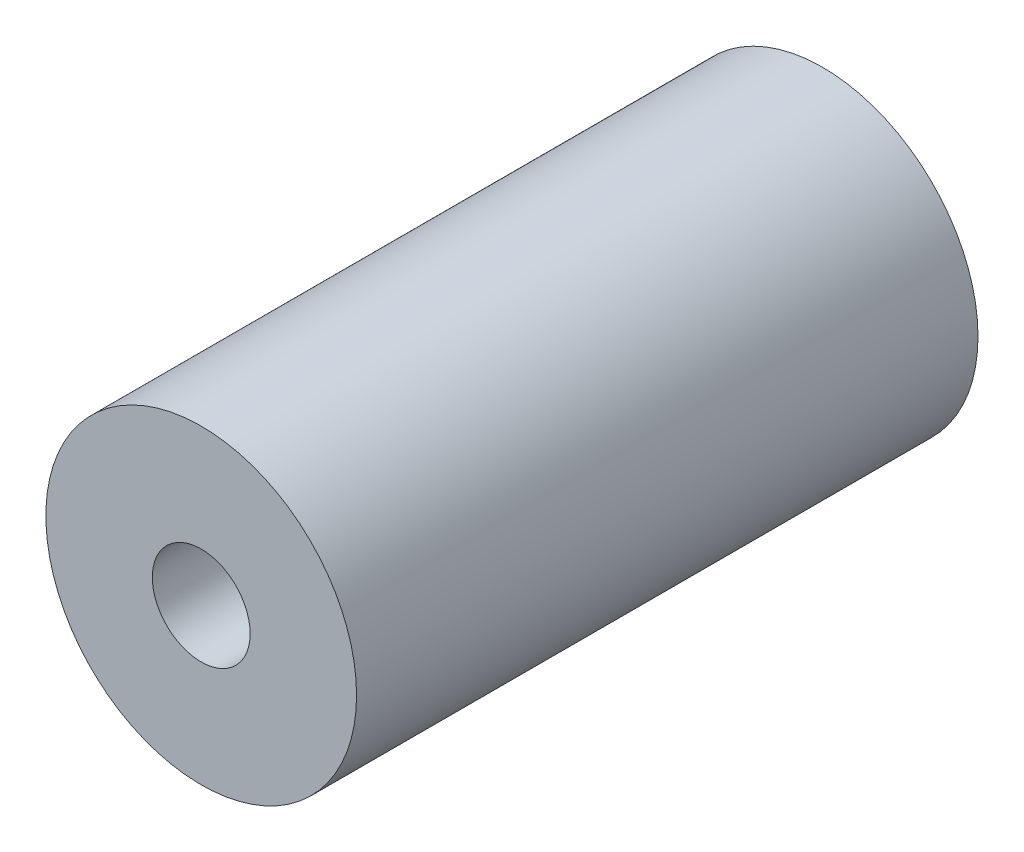
from build123d import *

# Parameters (mm, degrees)
SKETCH1_R           = 6.35
SKETCH1_R_2         = 2
BOSS_EXTRUDE1_DEPTH = 25.4


with BuildPart() as part:
    # Sketch1 → Boss-Extrude1 (new body)
    with BuildSketch(Plane.XY):
        Circle(SKETCH1_R)
        Circle(SKETCH1_R_2, mode=Mode.SUBTRACT)
    extrude(amount=BOSS_EXTRUDE1_DEPTH)


solid = part.part
